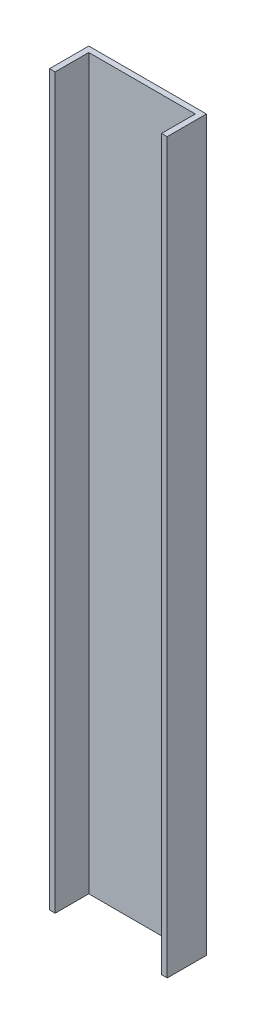
from build123d import *

# Parameters (mm, degrees)
BOSS_EXTRUDE1_DEPTH = 1300


with BuildPart() as part:
    # Sketch1 → Boss-Extrude1 (new body)
    with BuildSketch(Plane(origin=(0, 2350, 0), x_dir=(1, 0, 0), z_dir=(0, 1, 0))):
        Polygon((-10, 70), (-10, 0), (0, 0), (0, 60), (190, 60), (190, 0), (200, 0), (200, 70), align=None)
    extrude(amount=-BOSS_EXTRUDE1_DEPTH)


solid = part.part
